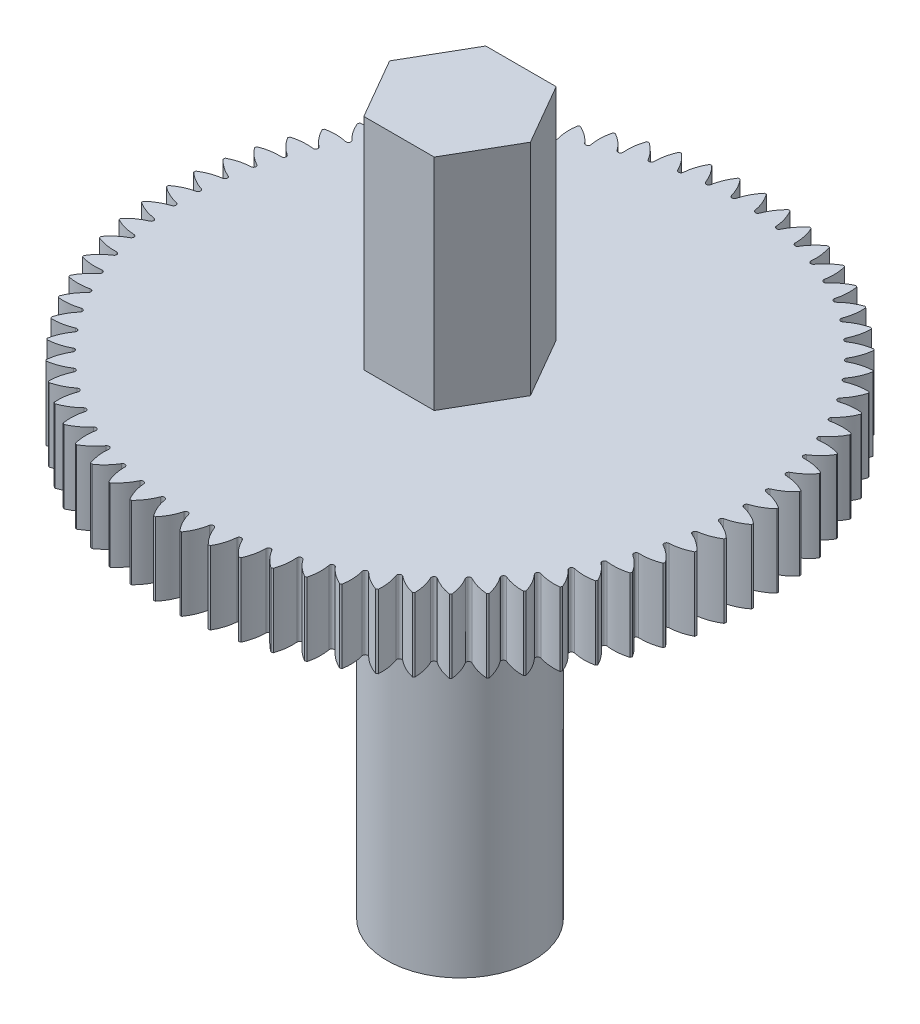
from build123d import *

# Parameters (mm, degrees)
CUT_EXTRUDE1_DEPTH = 3
CIRPATTERN1_COUNT  = 70
SKETCH3_R          = 3
CUT_EXTRUDE2_DEPTH = 9


with BuildPart() as part:
    # Sketch1 → Revolve1 (revolve)
    with BuildSketch(Plane.XY):
        Polygon((3, 20), (3, 29), (0, 29), (0, 0), (3, 0), (3, 17), (12, 17), (12, 20), align=None)
    revolve(axis=Axis((0, 0, 0), (0, 1, 0)))

    # Sketch2 → Cut-Extrude1 (cut)
    with BuildSketch(Plane(origin=(0, 20, 0), x_dir=(1, 0, 0), z_dir=(0, 1, 0))):
        with BuildLine():
            ThreePointArc((-0.5, 11.989578808), (0, 12), (0.5, 11.989578808))
            ThreePointArc((0.5, 11.989578808), (0.256290934, 11.628706779), (0.096463593, 11.223641412))
            ThreePointArc((0.096463593, 11.223641412), (0, 11.15), (-0.096463593, 11.223641412))
            ThreePointArc((-0.096463593, 11.223641412), (-0.256290934, 11.628706779), (-0.5, 11.989578808))
        make_face()
    cut_extrude1 = extrude(amount=-CUT_EXTRUDE1_DEPTH, mode=Mode.SUBTRACT)

    # CirPattern1: Cut-Extrude1 ×70 about axis
    cirpattern1_axis = Axis((0, 0, 0), (0, 1, 0))
    for i in range(1, CIRPATTERN1_COUNT):
        add(cut_extrude1.rotate(cirpattern1_axis, i * 360 / CIRPATTERN1_COUNT), mode=Mode.SUBTRACT)

    # Sketch3 → Cut-Extrude2 (cut)
    with BuildSketch(Plane(origin=(0, 29, 0), x_dir=(1, 0, 0), z_dir=(0, 1, 0))):
        Circle(SKETCH3_R)
        Polygon((-1.443375673, 2.5), (-2.886751346, 0), (-1.443375673, -2.5), (1.443375673, -2.5), (2.886751346, 0), (1.443375673, 2.5), align=None, mode=Mode.SUBTRACT)
    extrude(amount=-CUT_EXTRUDE2_DEPTH, mode=Mode.SUBTRACT)


solid = part.part
